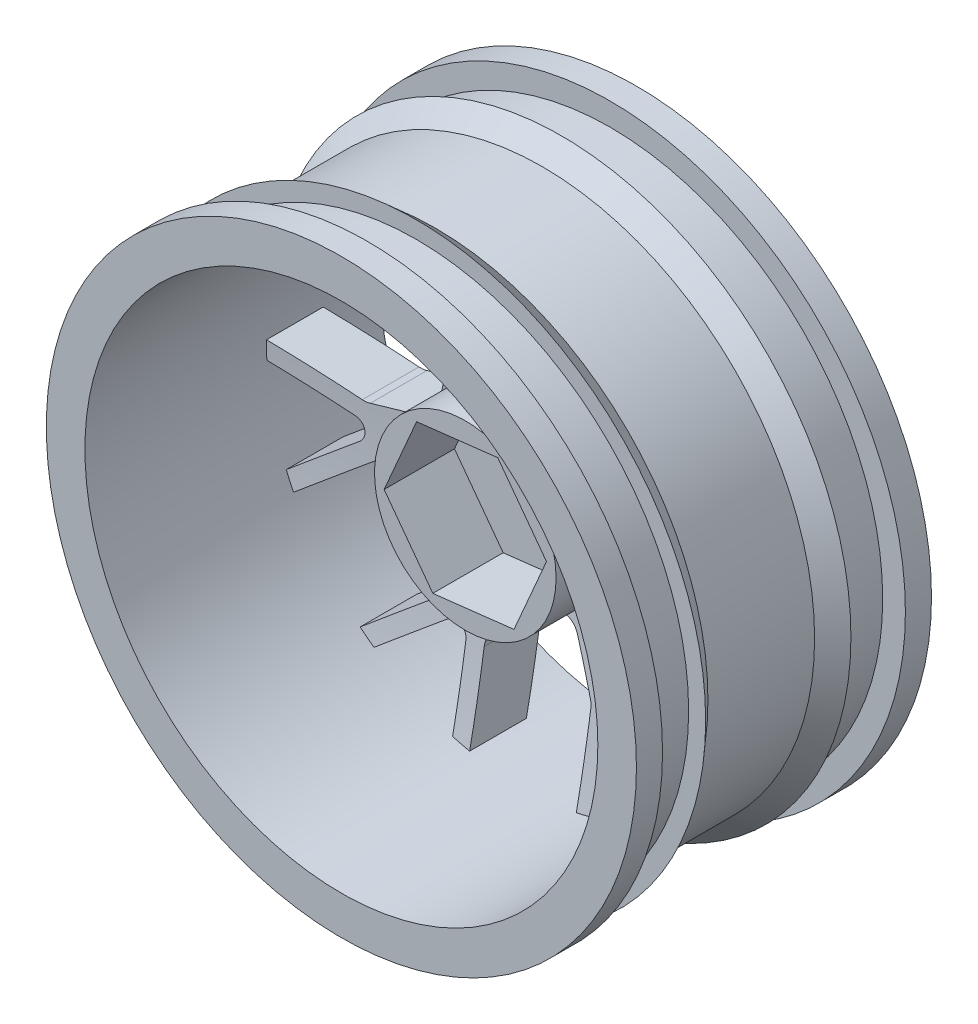
from build123d import *

# Parameters (mm, degrees)
CUT_EXTRUDE1_DEPTH      = 46.033320997
CUT_EXTRUDE1_DEPTH_BACK = 46.033320997
SKETCH8_R               = 8
CUT_EXTRUDE2_DEPTH      = 3
SKETCH9_R               = 8
BOSS_EXTRUDE1_DEPTH     = 8.62905658
BOSS_EXTRUDE2_START     = 0.8
SKETCH10_R              = 8
SKETCH10_R_2            = 6
BOSS_EXTRUDE2_DEPTH     = 0.8
CUT_EXTRUDE3_DEPTH      = 0.8
CUT_EXTRUDE4_DEPTH      = 43.195852877
CUT_EXTRUDE4_DEPTH_BACK = 43.195852877
SKETCH13_R              = 2.25
BOSS_EXTRUDE3_REACH     = 43.059
SKETCH14_R              = 2.25
SKETCH15_R              = 2.25
BOSS_EXTRUDE4_DEPTH     = 1.15094342
SKETCH16_R              = 8
BOSS_EXTRUDE5_DEPTH     = 1.15094342


with BuildPart() as part:
    # Sketch4 → Revolve1 (revolve)
    with BuildSketch(Plane(origin=(0, 0, 0), x_dir=(0, 0, -1), z_dir=(1, 0, 0)), mode=Mode.PRIVATE) as revolve1_sk:
        Polygon((0, 22.6), (0, 26), (2.3, 26), (2.3, 24), (6.6, 24), (6.6, 25.5), (8.3, 24), (17.7, 24), (19.4, 25.5), (19.4, 24), (23.7, 24), (23.7, 26), (26, 26), (26, 22.6), align=None)
    revolve(revolve1_sk.sketch.rotate(Axis((0, 0, 0), (0, 0, -1)), 90), axis=Axis((0, 0, 0), (0, 0, -1)))

    # Sketch6 → Revolve2 (revolve)
    with BuildSketch(Plane(origin=(0, 0, 0), x_dir=(0, 0, -1), z_dir=(1, 0, 0)), mode=Mode.PRIVATE) as revolve2_sk:
        with BuildLine():
            Line((23.7, 0), (18.7, 0))
            add(Edge.make_bspline(
                [(16, -22.6), (18.332324208, -11.421730045), (18.7, 0)],
                knots=[0, 0, 0, 1, 1, 1], degree=2))
            Line((16, -22.6), (21, -22.6))
            add(Edge.make_bspline(
                [(21, -22.6), (23.332324208, -11.421730045), (23.7, 0)],
                knots=[0, 0, 0, 1, 1, 1], degree=2))
        make_face()
    revolve(revolve2_sk.sketch.rotate(Axis((0, 0, 0), (0, 0, -1)), 270), axis=Axis((0, 0, 0), (0, 0, -1)))

    # Sketch7 → Cut-Extrude1 (cut, two sides: drawn at the far end of the back side and taken through both)
    with BuildSketch(Plane(origin=(0, 0, -26), x_dir=(-1, 0, 0), z_dir=(0, 0, -1)).offset(-CUT_EXTRUDE1_DEPTH_BACK)):
        with BuildLine():
            ThreePointArc((2.894192515, -10.345892079), (2.340926657, -9.693783084), (1.521219966, -9.45))
            Line((1.521219966, -9.45), (-1.521219966, -9.45))
            ThreePointArc((-1.521219966, -9.45), (-2.340926657, -9.693783084), (-2.894192515, -10.345892079))
            Line((-2.894192515, -10.345892079), (-4.572972549, -14.161301247))
            ThreePointArc((-4.572972549, -14.161301247), (-4.66789966, -14.456749828), (-4.7, -14.765409168))
            Line((-4.7, -14.765409168), (-4.7, -22.10588157))
            ThreePointArc((-4.7, -22.10588157), (0, -22.6), (4.7, -22.10588157))
            Line((4.7, -22.10588157), (4.7, -14.765409168))
            ThreePointArc((4.7, -14.765409168), (4.66789966, -14.456749828), (4.572972549, -14.161301247))
            Line((4.572972549, -14.161301247), (2.894192515, -10.345892079))
        make_face()
        with BuildLine():
            Line((-14.352672091, -17.457399688), (-8.613659671, -12.880690004))
            ThreePointArc((-8.613659671, -12.880690004), (-8.392354315, -12.663146997), (-8.220549399, -12.404720815))
            Line((-8.220549399, -12.404720815), (-6.284244624, -8.713329026))
            ThreePointArc((-6.284244624, -8.713329026), (-6.119360902, -7.874185052), (-6.439842374, -7.081316289))
            Line((-6.439842374, -7.081316289), (-8.336772644, -4.702640966))
            ThreePointArc((-8.336772644, -4.702640966), (-9.038448696, -4.213764736), (-9.893243659, -4.187787378))
            Line((-9.893243659, -4.187787378), (-13.922952896, -5.254133002))
            ThreePointArc((-13.922952896, -5.254133002), (-14.213129984, -5.364125175), (-14.474463808, -5.531474069))
            Line((-14.474463808, -5.531474069), (-20.213476228, -10.108183753))
            ThreePointArc((-20.213476228, -10.108183753), (-17.669391504, -14.090869522), (-14.352672091, -17.457399688))
        make_face()
        with BuildLine():
            Line((-22.597489356, 0.336860226), (-15.441057923, -1.296548549))
            ThreePointArc((-15.441057923, -1.296548549), (-15.132994318, -1.333936196), (-14.823829981, -1.3071326))
            Line((-14.823829981, -1.3071326), (-10.730517385, -0.519451498))
            ThreePointArc((-10.730517385, -0.519451498), (-9.971644889, -0.125165073), (-9.551572058, 0.619743021))
            Line((-9.551572058, 0.619743021), (-8.874565483, 3.585902631))
            ThreePointArc((-8.874565483, 3.585902631), (-8.929834517, 4.439304403), (-9.442480542, 5.123806634))
            Line((-9.442480542, 5.123806634), (-12.788665736, 7.609504559))
            ThreePointArc((-12.788665736, 7.609504559), (-13.055583535, 7.767795143), (-13.349361143, 7.867773826))
            Line((-13.349361143, 7.867773826), (-20.505792577, 9.5011826))
            ThreePointArc((-20.505792577, 9.5011826), (-22.033370815, 5.028973107), (-22.597489356, 0.336860226))
        make_face()
        with BuildLine():
            Line((-13.825936231, 17.877457519), (-10.641024619, 11.263920409))
            ThreePointArc((-10.641024619, 11.263920409), (-10.478180943, 10.999755768), (-10.264464236, 10.774753124))
            Line((-10.264464236, 10.774753124), (-7.096491693, 8.065583604))
            ThreePointArc((-7.096491693, 8.065583604), (-6.31507689, 7.71810676), (-5.470773165, 7.854123195))
            Line((-5.470773165, 7.854123195), (-2.729629504, 9.174188409))
            ThreePointArc((-2.729629504, 9.174188409), (-2.096872811, 9.749486781), (-1.881336986, 10.577069743))
            Line((-1.881336986, 10.577069743), (-2.024252436, 14.743029981))
            ThreePointArc((-2.024252436, 14.743029981), (-2.066916399, 15.050407284), (-2.17191726, 15.342427556))
            Line((-2.17191726, 15.342427556), (-5.356828873, 21.955964666))
            ThreePointArc((-5.356828873, 21.955964666), (-9.805772504, 20.361896415), (-13.825936231, 17.877457519))
        make_face()
        with BuildLine():
            Line((5.356828873, 21.955964666), (2.17191726, 15.342427556))
            ThreePointArc((2.17191726, 15.342427556), (2.066916399, 15.050407284), (2.024252436, 14.743029981))
            Line((2.024252436, 14.743029981), (1.881336986, 10.577069743))
            ThreePointArc((1.881336986, 10.577069743), (2.096872811, 9.749486781), (2.729629504, 9.174188409))
            Line((2.729629504, 9.174188409), (5.470773165, 7.854123195))
            ThreePointArc((5.470773165, 7.854123195), (6.31507689, 7.71810676), (7.096491693, 8.065583604))
            Line((7.096491693, 8.065583604), (10.264464236, 10.774753124))
            ThreePointArc((10.264464236, 10.774753124), (10.478180943, 10.999755768), (10.641024619, 11.263920409))
            Line((10.641024619, 11.263920409), (13.825936231, 17.877457519))
            ThreePointArc((13.825936231, 17.877457519), (9.805772504, 20.361896415), (5.356828873, 21.955964666))
        make_face()
        with BuildLine():
            Line((20.505792577, 9.5011826), (13.349361143, 7.867773826))
            ThreePointArc((13.349361143, 7.867773826), (13.055583535, 7.767795143), (12.788665736, 7.609504559))
            Line((12.788665736, 7.609504559), (9.442480542, 5.123806634))
            ThreePointArc((9.442480542, 5.123806634), (8.929834517, 4.439304403), (8.874565483, 3.585902631))
            Line((8.874565483, 3.585902631), (9.551572058, 0.619743021))
            ThreePointArc((9.551572058, 0.619743021), (9.971644889, -0.125165073), (10.730517385, -0.519451498))
            Line((10.730517385, -0.519451498), (14.823829981, -1.3071326))
            ThreePointArc((14.823829981, -1.3071326), (15.132994318, -1.333936196), (15.441057923, -1.296548549))
            Line((15.441057923, -1.296548549), (22.597489356, 0.336860226))
            ThreePointArc((22.597489356, 0.336860226), (22.033370815, 5.028973107), (20.505792577, 9.5011826))
        make_face()
        with BuildLine():
            Line((20.213476228, -10.108183753), (14.474463808, -5.531474069))
            ThreePointArc((14.474463808, -5.531474069), (14.213129984, -5.364125175), (13.922952896, -5.254133002))
            Line((13.922952896, -5.254133002), (9.893243659, -4.187787378))
            ThreePointArc((9.893243659, -4.187787378), (9.038448696, -4.213764736), (8.336772644, -4.702640966))
            Line((8.336772644, -4.702640966), (6.439842374, -7.081316289))
            ThreePointArc((6.439842374, -7.081316289), (6.119360902, -7.874185052), (6.284244624, -8.713329026))
            Line((6.284244624, -8.713329026), (8.220549399, -12.404720815))
            ThreePointArc((8.220549399, -12.404720815), (8.392354315, -12.663146997), (8.613659671, -12.880690004))
            Line((8.613659671, -12.880690004), (14.352672091, -17.457399688))
            ThreePointArc((14.352672091, -17.457399688), (17.669391504, -14.090869522), (20.213476228, -10.108183753))
        make_face()
        with BuildLine():
            Line((6.2, -14.950954055), (6.2, -21.732924332))
            ThreePointArc((6.2, -21.732924332), (9.805772504, -20.361896415), (13.125847677, -18.397611877))
            Line((13.125847677, -18.397611877), (7.823489802, -14.169122573))
            ThreePointArc((7.823489802, -14.169122573), (6.766116261, -14.049985187), (6.2, -14.950954055))
        make_face()
        with BuildLine():
            Line((-7.823489802, -14.169122573), (-13.125847677, -18.397611877))
            ThreePointArc((-13.125847677, -18.397611877), (-9.805772504, -20.361896415), (-6.2, -21.732924332))
            Line((-6.2, -21.732924332), (-6.2, -14.950954055))
            ThreePointArc((-6.2, -14.950954055), (-6.766116261, -14.049985187), (-7.823489802, -14.169122573))
        make_face()
        with BuildLine():
            Line((-15.955732213, -2.717652796), (-22.567664335, -1.208522436))
            ThreePointArc((-22.567664335, -1.208522436), (-22.033370815, -5.028973107), (-20.85712122, -8.702901494))
            Line((-20.85712122, -8.702901494), (-15.554763345, -4.47441219))
            ThreePointArc((-15.554763345, -4.47441219), (-15.203325235, -3.470059774), (-15.955732213, -2.717652796))
        make_face()
        with BuildLine():
            Line((-12.07298283, 10.780264967), (-15.015569452, 16.890609049))
            ThreePointArc((-15.015569452, 16.890609049), (-17.669391504, 14.090869522), (-19.808404754, 10.880583675))
            Line((-19.808404754, 10.880583675), (-13.196472632, 9.371453315))
            ThreePointArc((-13.196472632, 9.371453315), (-12.192120215, 9.722891426), (-12.07298283, 10.780264967))
        make_face()
        with BuildLine():
            Line((0.900968868, 16.160423332), (3.84355549, 22.270767414))
            ThreePointArc((3.84355549, 22.270767414), (0, 22.6), (-3.84355549, 22.270767414))
            Line((-3.84355549, 22.270767414), (-0.900968868, 16.160423332))
            ThreePointArc((-0.900968868, 16.160423332), (0, 15.594307071), (0.900968868, 16.160423332))
        make_face()
        with BuildLine():
            Line((13.196472632, 9.371453315), (19.808404754, 10.880583675))
            ThreePointArc((19.808404754, 10.880583675), (17.669391504, 14.090869522), (15.015569452, 16.890609049))
            Line((15.015569452, 16.890609049), (12.07298283, 10.780264967))
            ThreePointArc((12.07298283, 10.780264967), (12.192120215, 9.722891426), (13.196472632, 9.371453315))
        make_face()
        with BuildLine():
            Line((15.554763345, -4.47441219), (20.85712122, -8.702901494))
            ThreePointArc((20.85712122, -8.702901494), (22.033370815, -5.028973107), (22.567664335, -1.208522436))
            Line((22.567664335, -1.208522436), (15.955732213, -2.717652796))
            ThreePointArc((15.955732213, -2.717652796), (15.203325235, -3.470059774), (15.554763345, -4.47441219))
        make_face()
    extrude(amount=CUT_EXTRUDE1_DEPTH + CUT_EXTRUDE1_DEPTH_BACK, mode=Mode.SUBTRACT)

    # Sketch8 → Cut-Extrude2 (cut)
    with BuildSketch(Plane(origin=(0, 0, -23.7), x_dir=(-1, 0, 0), z_dir=(0, 0, -1))):
        Circle(SKETCH8_R)
    extrude(amount=-CUT_EXTRUDE2_DEPTH, mode=Mode.SUBTRACT)

    # Sketch9 → Boss-Extrude1 (add)
    with BuildSketch(Plane(origin=(0, 0, -20.7), x_dir=(-1, 0, 0), z_dir=(0, 0, -1))):
        Circle(SKETCH9_R)
        Polygon((4.290354408, 5.782115448), (-2.862281661, 6.606613633), (-7.15263607, 0.824498185), (-4.290354408, -5.782115448), (2.862281661, -6.606613633), (7.15263607, -0.824498185), align=None, mode=Mode.SUBTRACT)
    extrude(amount=-BOSS_EXTRUDE1_DEPTH)

    # Sketch10 → Boss-Extrude2 (add)
    with BuildSketch(Plane(origin=(0, 0, -20.7), x_dir=(-1, 0, 0), z_dir=(0, 0, -1)).offset(BOSS_EXTRUDE2_START)):
        Circle(SKETCH10_R)
        Circle(SKETCH10_R_2, mode=Mode.SUBTRACT)
    extrude(amount=-BOSS_EXTRUDE2_DEPTH)

    # Sketch11 → Cut-Extrude3 (cut)
    with BuildSketch(Plane(origin=(0, 0, -21.5), x_dir=(-1, 0, 0), z_dir=(0, 0, -1))):
        with BuildLine():
            ThreePointArc((5.846153846, -1.349994521), (8, 0), (5.846153846, 1.349994521))
            ThreePointArc((5.846153846, 1.349994521), (6, 0), (5.846153846, -1.349994521))
        make_face()
        with BuildLine():
            ThreePointArc((0.522639804, -5.97719396), (1.854101966, -5.706339098), (3.090481976, -5.142851461))
            ThreePointArc((3.090481976, -5.142851461), (2.472135955, -7.60845213), (0.522639804, -5.97719396))
        make_face()
        with BuildLine():
            ThreePointArc((-5.523144683, -2.344114503), (-4.854101966, -3.526711514), (-3.936130943, -4.528451523))
            ThreePointArc((-3.936130943, -4.528451523), (-6.472135955, -4.702282018), (-5.523144683, -2.344114503))
        make_face()
        with BuildLine():
            ThreePointArc((-3.936130943, 4.528451523), (-4.854101966, 3.526711514), (-5.523144683, 2.344114503))
            ThreePointArc((-5.523144683, 2.344114503), (-6.472135955, 4.702282018), (-3.936130943, 4.528451523))
        make_face()
        with BuildLine():
            ThreePointArc((3.090481976, 5.142851461), (1.854101966, 5.706339098), (0.522639804, 5.97719396))
            ThreePointArc((0.522639804, 5.97719396), (2.472135955, 7.60845213), (3.090481976, 5.142851461))
        make_face()
    extrude(amount=-CUT_EXTRUDE3_DEPTH, mode=Mode.SUBTRACT)

    # Sketch13 → Cut-Extrude4 (cut, two sides: drawn at the far end of the back side and taken through both)
    with BuildSketch(Plane(origin=(0, 0, -20.7), x_dir=(-1, 0, 0), z_dir=(0, 0, -1)).offset(-CUT_EXTRUDE4_DEPTH_BACK)):
        Circle(SKETCH13_R)
    extrude(amount=CUT_EXTRUDE4_DEPTH + CUT_EXTRUDE4_DEPTH_BACK, mode=Mode.SUBTRACT)

    # Sketch14 → Boss-Extrude3 (add, up to next)
    with BuildSketch(Plane.XY.offset(-18.270943423), mode=Mode.PRIVATE) as boss_extrude3_sk1:
        Polygon((2.862281661, 6.606613633), (-4.290354408, 5.782115448), (-7.15263607, -0.824498185), (-2.862281661, -6.606613633), (4.290354408, -5.782115448), (7.15263607, 0.824498185), align=None)
        with Locations(Location((0, 0, 0), (0, 0, 180))):
            Circle(SKETCH14_R, mode=Mode.SUBTRACT)
    boss_extrude3_tool1 = extrude(boss_extrude3_sk1.sketch, amount=-BOSS_EXTRUDE3_REACH, mode=Mode.PRIVATE) - part.part
    add(boss_extrude3_tool1.solids().sort_by_distance((-0.691736, 6.000907, -18.270943))[0])

    # Sketch15 → Boss-Extrude4 (add)
    with BuildSketch(Plane.XY.offset(-18.270943423)):
        Polygon((-4.290354408, 5.782115448), (-7.15263607, -0.824498185), (-2.862281661, -6.606613633), (4.290354408, -5.782115448), (7.15263607, 0.824498185), (2.862281661, 6.606613633), align=None)
        with Locations(Location((0, 0, 0), (0, 0, 180))):
            Circle(SKETCH15_R, mode=Mode.SUBTRACT)
    extrude(amount=BOSS_EXTRUDE4_DEPTH)

    # Sketch16 → Boss-Extrude5 (add)
    with BuildSketch(Plane.XY.offset(-12.07094342)):
        with Locations(Location((0, 0, 0), (0, 0, 180))):
            Circle(SKETCH16_R)
        Polygon((4.290354408, -5.782115448), (-2.862281661, -6.606613633), (-7.15263607, -0.824498185), (-4.290354408, 5.782115448), (2.862281661, 6.606613633), (7.15263607, 0.824498185), align=None, mode=Mode.SUBTRACT)
    extrude(amount=BOSS_EXTRUDE5_DEPTH)


solid = part.part
